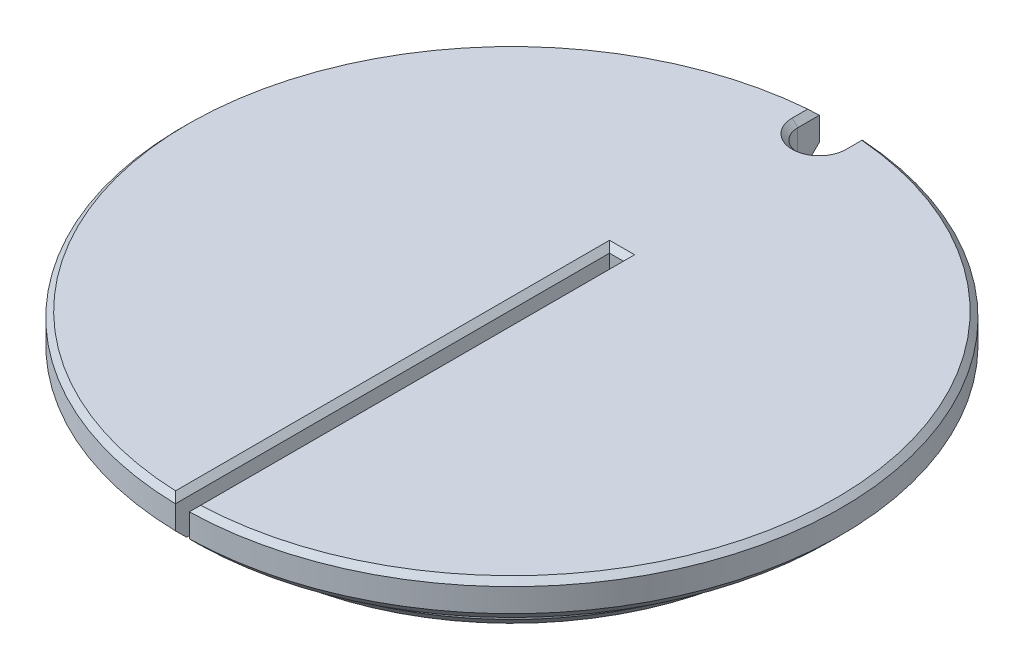
from build123d import *

# Parameters (mm, degrees)
CUT_EXTRUDE2_DEPTH = 8.62
CUT_EXTRUDE3_DEPTH = 8.62
CHAMFER1_SIZE      = 1.016
CHAMFER2_SIZE      = 0.508


with BuildPart() as part:
    # Sketch1 → Revolve1 (revolve)
    with BuildSketch(Plane.XY):
        Polygon((0, 0), (0, -7.62), (25.0698, -7.62), (25.0698, -3.6576), (30.0228, -3.6576), (30.0228, 0), align=None)
    revolve(axis=Axis((0, -1000, 0), (0, 1, 0)))

    # Sketch3 → Cut-Extrude2 (cut, through all)
    with BuildSketch(Plane(origin=(0, 0, 0), x_dir=(1, 0, 0), z_dir=(0, 1, 0))):
        with BuildLine():
            Line((-0.635, 9.525), (0.635, 9.525))
            Line((0.635, 9.525), (0.635, -30.016083936))
            ThreePointArc((0.635, -30.016083936), (0, -30.0228), (-0.635, -30.016083936))
            Line((-0.635, -30.016083936), (-0.635, 9.525))
        make_face()
    extrude(amount=-CUT_EXTRUDE2_DEPTH, mode=Mode.SUBTRACT)

    # Sketch5 → Cut-Extrude3 (cut, through all)
    with BuildSketch(Plane(origin=(0, 0, 0), x_dir=(1, 0, 0), z_dir=(0, 1, 0))):
        with BuildLine():
            Line((-1.9558, 29.959028125), (-1.9558, 27.9908))
            ThreePointArc((-1.9558, 27.9908), (0, 26.035), (1.9558, 27.9908))
            Line((1.9558, 27.9908), (1.9558, 29.959028125))
            ThreePointArc((1.9558, 29.959028125), (0, 30.0228), (-1.9558, 29.959028125))
        make_face()
    extrude(amount=-CUT_EXTRUDE3_DEPTH, mode=Mode.SUBTRACT)

    # Chamfer1
    chamfer1_edges = [part.edges().sort_by_distance(p)[0] for p in [
        (-30.015522282, -3.6576, 0.661015886),
        (-17.501079239, -7.62, -17.950128064),
        (30.015522282, -3.6576, 0.661015886),
    ]]
    chamfer(chamfer1_edges, length=CHAMFER1_SIZE)

    # Chamfer2
    chamfer2_edges = [part.edges().sort_by_distance(p)[0] for p in [
        (-30.015522282, 0, 0.661015886),
        (-0.635, 0, 10.245541968),
        (0.635, 0, 10.245541968),
        (0, 0, -9.525),
        (30.015522282, 0, 0.661015886),
        (-1.9558, 0, -28.974914063),
        (0, 0, -26.035),
        (1.9558, 0, -28.974914063),
    ]]
    chamfer(chamfer2_edges, length=CHAMFER2_SIZE)


solid = part.part
